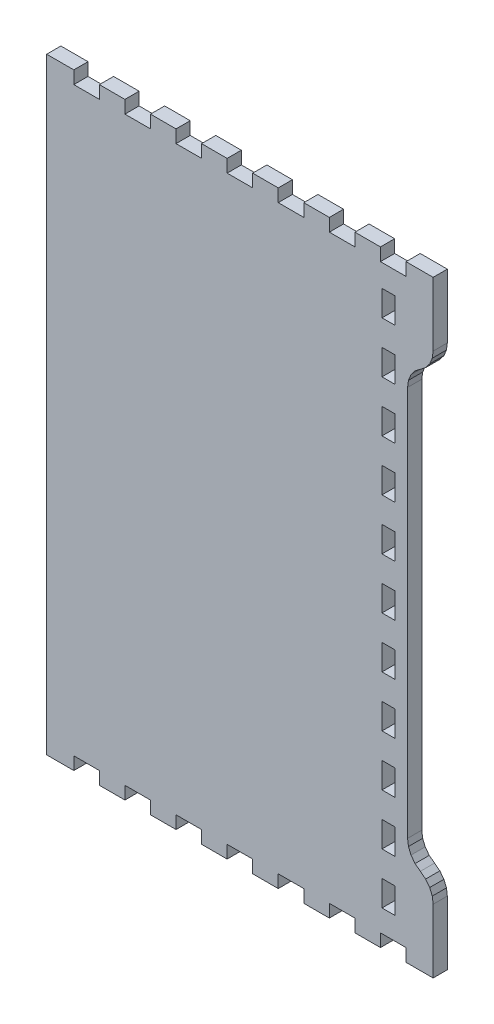
from build123d import *

# Parameters (mm, degrees)
BOSS_EXTRUDE1_DEPTH = 6.35


with BuildPart() as part:
    # Model → Boss-Extrude1 (new body)
    with BuildSketch(Plane.XY):
        Polygon((1288.610132665, 22.860238699), (1300.745973293, 22.860238699), (1300.745973293, 28.575245224), (1312.176695005, 28.575245224), (1312.176695005, 22.860238699), (1323.607416717, 22.860238699), (1323.607416717, 28.575245224), (1335.038138429, 28.575245224), (1335.038138429, 22.860238699), (1346.46531683, 22.860238699), (1346.46531683, 28.575245224), (1357.896038543, 28.575245224), (1357.896038543, 22.860238699), (1369.326760255, 22.860238699), (1369.326760255, 28.575245224), (1380.757481967, 28.575245224), (1380.757481967, 22.860238699), (1392.188203679, 22.860238699), (1392.188203679, 28.575245224), (1403.615382081, 28.575245224), (1403.615382081, 22.860238699), (1415.046103793, 22.860238699), (1415.046103793, 28.575245224), (1426.476825505, 28.575245224), (1426.476825505, 22.860238699), (1437.907547217, 22.860238699), (1437.907547217, 28.575245224), (1449.33826893, 28.575245224), (1449.33826893, 22.860238699), (1461.470566246, 22.860238699), (1461.470566246, 28.575245224), (1461.470566246, 51.435413056), (1461.081244935, 54.393369189), (1459.939855837, 57.150419581), (1458.123908882, 59.517571103), (1455.75520539, 61.334361366), (1453.389602295, 63.150485487), (1451.574098254, 65.517240157), (1450.429608758, 68.274290549), (1450.039844534, 71.232246682), (1450.039844534, 245.918194159), (1450.429608758, 248.876284937), (1451.574098254, 251.633200684), (1453.389602295, 254.00013252), (1455.75520539, 255.816433806), (1458.123908882, 257.633089424), (1459.939855837, 260.000375591), (1461.081244935, 262.757291337), (1461.470566246, 265.715382116), (1461.470566246, 288.575408216), (1461.470566246, 294.290414741), (1449.33826893, 294.290414741), (1449.33826893, 288.575408216), (1437.907547217, 288.575408216), (1437.907547217, 294.290414741), (1426.476825505, 294.290414741), (1426.476825505, 288.575408216), (1415.046103793, 288.575408216), (1415.046103793, 294.290414741), (1403.615382081, 294.290414741), (1403.615382081, 288.575408216), (1392.188203679, 288.575408216), (1392.188203679, 294.290414741), (1380.757481967, 294.290414741), (1380.757481967, 288.575408216), (1369.326760255, 288.575408216), (1369.326760255, 294.290414741), (1357.896038543, 294.290414741), (1357.896038543, 288.575408216), (1346.46531683, 288.575408216), (1346.46531683, 294.290414741), (1335.038138429, 294.290414741), (1335.038138429, 288.575408216), (1323.607416717, 288.575408216), (1323.607416717, 294.290414741), (1312.176695005, 294.290414741), (1312.176695005, 288.575408216), (1300.745973293, 288.575408216), (1300.745973293, 294.290414741), (1288.610132665, 294.290414741), (1288.610132665, 288.575408216), (1288.610132665, 28.575245224), align=None)
        Polygon((1444.328026989, 44.27508992), (1444.328026989, 38.560083395), (1438.612666133, 38.560083395), (1438.612666133, 49.990096445), (1444.328026989, 49.990096445), align=None, mode=Mode.SUBTRACT)
        Polygon((1444.328026989, 67.13511602), (1444.328026989, 61.420109495), (1438.612666133, 61.420109495), (1438.612666133, 72.850122545), (1444.328026989, 72.850122545), align=None, mode=Mode.SUBTRACT)
        Polygon((1444.328026989, 89.99514212), (1444.328026989, 84.280135595), (1438.612666133, 84.280135595), (1438.612666133, 95.710148645), (1444.328026989, 95.710148645), align=None, mode=Mode.SUBTRACT)
        Polygon((1444.328026989, 112.85516822), (1444.328026989, 107.140161695), (1438.612666133, 107.140161695), (1438.612666133, 118.570174745), (1444.328026989, 118.570174745), align=None, mode=Mode.SUBTRACT)
        Polygon((1444.328026989, 135.71519432), (1444.328026989, 130.000187795), (1438.612666133, 130.000187795), (1438.612666133, 141.430200846), (1444.328026989, 141.430200846), align=None, mode=Mode.SUBTRACT)
        Polygon((1444.328026989, 158.575220421), (1444.328026989, 152.860213896), (1438.612666133, 152.860213896), (1438.612666133, 164.290226946), (1444.328026989, 164.290226946), align=None, mode=Mode.SUBTRACT)
        Polygon((1444.328026989, 181.435246521), (1444.328026989, 175.720239996), (1438.612666133, 175.720239996), (1438.612666133, 187.150253046), (1444.328026989, 187.150253046), align=None, mode=Mode.SUBTRACT)
        Polygon((1444.328026989, 204.295272621), (1444.328026989, 198.580266096), (1438.612666133, 198.580266096), (1438.612666133, 210.010279146), (1444.328026989, 210.010279146), align=None, mode=Mode.SUBTRACT)
        Polygon((1444.328026989, 227.155298721), (1444.328026989, 221.440292196), (1438.612666133, 221.440292196), (1438.612666133, 232.870305246), (1444.328026989, 232.870305246), align=None, mode=Mode.SUBTRACT)
        Polygon((1444.328026989, 250.015324821), (1444.328026989, 244.300318296), (1438.612666133, 244.300318296), (1438.612666133, 255.730331346), (1444.328026989, 255.730331346), align=None, mode=Mode.SUBTRACT)
        Polygon((1444.328026989, 272.875350921), (1444.328026989, 267.160344396), (1438.612666133, 267.160344396), (1438.612666133, 278.590357446), (1444.328026989, 278.590357446), align=None, mode=Mode.SUBTRACT)
    extrude(amount=BOSS_EXTRUDE1_DEPTH)


solid = part.part
